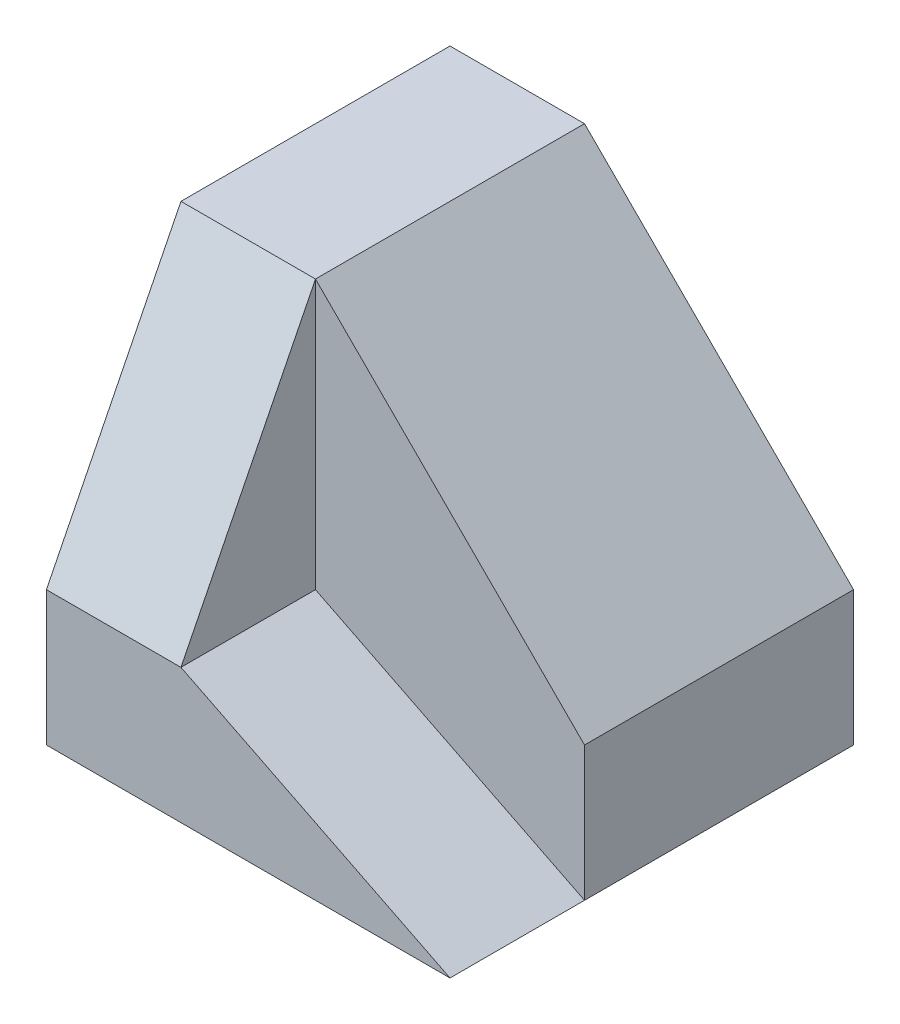
from build123d import *

# Parameters (mm, degrees)
CROQUIS1_W              = 60
CROQUIS1_H              = 60
SALIENTE_EXTRUIR1_DEPTH = 60
CROQUIS6_W              = 40
CROQUIS6_H              = 20
CORTAR_EXTRUIR2_DEPTH   = 40
CORTAR_EXTRUIR3_DEPTH   = 60
CORTAR_EXTRUIR4_DEPTH   = 20
CORTAR_EXTRUIR5_DEPTH   = 20


with BuildPart() as part:
    # Croquis1 → Saliente-Extruir1 (new body)
    with BuildSketch(Plane(origin=(0, 0, 0), x_dir=(1, 0, 0), z_dir=(0, 1, 0))):
        with Locations((30, -30)):
            Rectangle(CROQUIS1_W, CROQUIS1_H)
    extrude(amount=SALIENTE_EXTRUIR1_DEPTH)

    # Croquis6 → Cortar-Extruir2 (cut)
    with BuildSketch(Plane(origin=(0, 60, 0), x_dir=(1, 0, 0), z_dir=(0, 1, 0))):
        with Locations((40, -50)):
            Rectangle(CROQUIS6_W, CROQUIS6_H)
    extrude(amount=-CORTAR_EXTRUIR2_DEPTH, mode=Mode.SUBTRACT)

    # Croquis2 → Cortar-Extruir3 (cut)
    with BuildSketch(Plane.XY.offset(60)):
        Polygon((60, 60), (20, 60), (60, 20), align=None)
    extrude(amount=-CORTAR_EXTRUIR3_DEPTH, mode=Mode.SUBTRACT)

    # Croquis7 → Cortar-Extruir4 (cut)
    with BuildSketch(Plane.XY.offset(60)):
        Polygon((20, 20), (60, 0), (60, 20), align=None)
    extrude(amount=-CORTAR_EXTRUIR4_DEPTH, mode=Mode.SUBTRACT)

    # Croquis8 → Cortar-Extruir5 (cut)
    with BuildSketch(Plane(origin=(20, 0, 0), x_dir=(0, 0, -1), z_dir=(1, 0, 0))):
        Polygon((-40, 60), (-60, 20), (-60, 60), align=None)
    extrude(amount=-CORTAR_EXTRUIR5_DEPTH, mode=Mode.SUBTRACT)


solid = part.part
